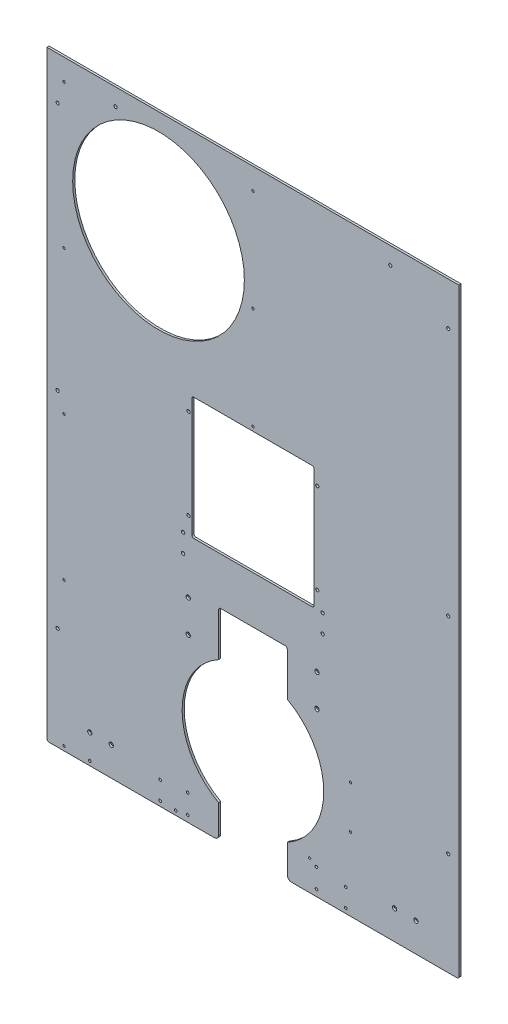
from build123d import *

# Parameters (mm, degrees)
SKETCH1_W                                     = 1219.2
SKETCH1_H                                     = 1778
SKETCH1_R                                     = 254
SKETCH1_W_2                                   = 361.95
SKETCH1_H_2                                   = 361.95
BOSS_EXTRUDE1_DEPTH                           = 6.35
SKETCH3_R                                     = 209.55
CUT_EXTRUDE2_DEPTH                            = 7.35
SKETCH2_W                                     = 203.2
SKETCH2_H                                     = 165.1
CUT_EXTRUDE1_DEPTH                            = 7.35
SKETCH4_R                                     = 3.3655
CUT_EXTRUDE3_DEPTH                            = 7.35
LPATTERN1_COUNT                               = 5
LPATTERN1_PITCH                               = 425.45
SKETCH5_R                                     = 3.429
CUT_EXTRUDE4_DEPTH                            = 7.35
LPATTERN2_COUNT                               = 3
LPATTERN2_PITCH                               = 301.625
SKETCH6_R                                     = 3.96875
CUT_EXTRUDE5_DEPTH                            = 7.35
SKETCH7_R                                     = 3.3782
CUT_EXTRUDE6_DEPTH                            = 7.35
CSK_FOR_1_4_FLAT_HEAD_MACHINE_SCREW1_AT_COUNT = 2
CSK_FOR_1_4_FLAT_HEAD_MACHINE_SCREW1_AT_PITCH = 63.5
LPATTERN3_COUNT                               = 2
LPATTERN3_PITCH                               = 901.7
SKETCH12_R                                    = 4.7625
CUT_EXTRUDE7_DEPTH                            = 7.35
SKETCH14_R                                    = 4.7625
CUT_EXTRUDE8_DEPTH                            = 7.35
SKETCH15_R                                    = 4.7625
CUT_EXTRUDE9_DEPTH                            = 7.35
SKETCH16_R                                    = 4.7625
CUT_EXTRUDE10_DEPTH                           = 7.35
FILLET1_R                                     = 12.7
FILLET2_R                                     = 6.35
SKETCH17_R                                    = 3.937
CUT_EXTRUDE11_DEPTH                           = 7.35
CSK_FOR_1_4_FLAT_HEAD_MACHINE_SCREW2_AT_COUNT = 2
CSK_FOR_1_4_FLAT_HEAD_MACHINE_SCREW2_AT_PITCH = 95.25
CSK_FOR_1_4_FLAT_HEAD_MACHINE_SCREW2_2_COUNT  = 2
CSK_FOR_1_4_FLAT_HEAD_MACHINE_SCREW2_2_PITCH  = 381
CSK_FOR_1_4_FLAT_HEAD_MACHINE_SCREW2_3_COUNT  = 2
CSK_FOR_1_4_FLAT_HEAD_MACHINE_SCREW2_3_PITCH  = 392.72581084
F_5_16_0_3125_DIAMETER_HOLE1_D                = 7.9375


with BuildPart() as part:
    # Sketch1 → Boss-Extrude1 (new body)
    with BuildSketch(Plane.XY):
        with Locations((609.6, 889)):
            Rectangle(SKETCH1_W, SKETCH1_H)
        with Locations((330.2, 1473.2)):
            Circle(SKETCH1_R, mode=Mode.SUBTRACT)
        with Locations((609.6, 917.575)):
            Rectangle(SKETCH1_W_2, SKETCH1_H_2, mode=Mode.SUBTRACT)
    extrude(amount=BOSS_EXTRUDE1_DEPTH)

    # Sketch3 → Cut-Extrude2 (cut, through all)
    with BuildSketch(Plane.XY.offset(6.35)):
        with Locations((609.6, 279.4)):
            Circle(SKETCH3_R)
    extrude(amount=-CUT_EXTRUDE2_DEPTH, mode=Mode.SUBTRACT)

    # Sketch2 → Cut-Extrude1 (cut, through all)
    with BuildSketch(Plane.XY.offset(6.35)):
        with Locations((609.6, 44.45)):
            Rectangle(SKETCH2_W, SKETCH2_H)
        with Locations((609.6, 514.35)):
            Rectangle(SKETCH2_W, SKETCH2_H)
    extrude(amount=-CUT_EXTRUDE1_DEPTH, mode=Mode.SUBTRACT)

    # Sketch4 → Cut-Extrude3 (cut, through all)
    with BuildSketch(Plane.XY.offset(6.35)):
        with Locations((50.8, 12.7)):
            Circle(SKETCH4_R)
    cut_extrude3 = extrude(amount=-CUT_EXTRUDE3_DEPTH, mode=Mode.SUBTRACT)

    # LPattern1: Cut-Extrude3 ×5
    with Locations(*[(0, i * LPATTERN1_PITCH, 0) for i in range(1, LPATTERN1_COUNT)]):
        add(cut_extrude3, mode=Mode.SUBTRACT)

    # Sketch5 → Cut-Extrude4 (cut, through all)
    with BuildSketch(Plane.XY.offset(6.35)):
        with Locations((609.6, 1714.5)):
            Circle(SKETCH5_R)
    cut_extrude4 = extrude(amount=-CUT_EXTRUDE4_DEPTH, mode=Mode.SUBTRACT)

    # LPattern2: Cut-Extrude4 ×3
    with Locations(*[(0, -i * LPATTERN2_PITCH, 0) for i in range(1, LPATTERN2_COUNT)]):
        add(cut_extrude4, mode=Mode.SUBTRACT)

    # Sketch6 → Cut-Extrude5 (cut, through all)
    with BuildSketch(Plane.XY.offset(6.35)):
        with Locations((127, 12.7)):
            Circle(SKETCH6_R)
        with Locations((381, 12.7)):
            Circle(SKETCH6_R)
    extrude(amount=-CUT_EXTRUDE5_DEPTH, mode=Mode.SUBTRACT)

    # Sketch7 → Cut-Extrude6 (cut, through all)
    with BuildSketch(Plane.XY.offset(6.35)):
        with Locations((777.605208253, 88.9)):
            Circle(SKETCH7_R)
        with Locations((898.525, 342.9)):
            Circle(SKETCH7_R)
        with Locations((898.525, 215.9)):
            Circle(SKETCH7_R)
    extrude(amount=-CUT_EXTRUDE6_DEPTH, mode=Mode.SUBTRACT)

    # Sketch11 → CSK for 1/4 Flat Head Machine Screw1 (revolve, cut)
    with BuildSketch(Plane(origin=(127, 85.725, 6.35), x_dir=(0, -1, 0), z_dir=(1, 0, 0))):
        Polygon((0, 0), (0, 6.35), (3.57124, 6.35), (3.57124, 3.298865467), (6.4389, 0), align=None)
    csk_for_1_4_flat_head_machine_screw1 = revolve(axis=Axis((127, 85.725, 12.7), (0, 0, -1)), mode=Mode.SUBTRACT)

    # CSK for 1/4 Flat Head Machine Screw1 at: CSK for 1/4 Flat Head Machine Screw1 ×2
    with Locations(*[(i * CSK_FOR_1_4_FLAT_HEAD_MACHINE_SCREW1_AT_PITCH, 0, 0) for i in range(1, CSK_FOR_1_4_FLAT_HEAD_MACHINE_SCREW1_AT_COUNT)]):
        add(csk_for_1_4_flat_head_machine_screw1, mode=Mode.SUBTRACT)

    # LPattern3: CSK for 1/4 Flat Head Machine Screw1 ×2
    with Locations(*[(i * LPATTERN3_PITCH, 0, 0) for i in range(1, LPATTERN3_COUNT)]):
        add(csk_for_1_4_flat_head_machine_screw1, mode=Mode.SUBTRACT)

    # LPattern3 copy 1 sketch → LPattern3 copy 1 (revolve, cut)
    with BuildSketch(Plane(origin=(1092.2, 85.725, 6.35), x_dir=(0, -1, 0), z_dir=(1, 0, 0))):
        Polygon((0, 0), (0, 6.35), (3.57124, 6.35), (3.57124, 3.298865467), (6.4389, 0), align=None)
    revolve(axis=Axis((1092.2, 85.725, 12.7), (0, 0, -1)), mode=Mode.SUBTRACT)

    # Sketch12 → Cut-Extrude7 (cut, through all)
    with BuildSketch(Plane.XY.offset(6.35)):
        with Locations((203.2, 1727.2)):
            Circle(SKETCH12_R)
        with Locations((1016, 1727.2)):
            Circle(SKETCH12_R)
    extrude(amount=-CUT_EXTRUDE7_DEPTH, mode=Mode.SUBTRACT)

    # Sketch14 → Cut-Extrude8 (cut, through all)
    with BuildSketch(Plane.XY.offset(6.35)):
        with Locations((31.75, 1651)):
            Circle(SKETCH14_R)
        with Locations((31.75, 914.4)):
            Circle(SKETCH14_R)
        with Locations((31.75, 304.8)):
            Circle(SKETCH14_R)
    cut_extrude8 = extrude(amount=-CUT_EXTRUDE8_DEPTH, mode=Mode.SUBTRACT)

    # Mirror1: Cut-Extrude8 across plane
    add(cut_extrude8.mirror(Plane.ZY.offset(-609.6)), mode=Mode.SUBTRACT)

    # Sketch15 → Cut-Extrude9 (cut, through all)
    with BuildSketch(Plane.XY.offset(6.35)):
        with Locations((403.225, 736.6)):
            Circle(SKETCH15_R)
        with Locations((403.225, 682.625)):
            Circle(SKETCH15_R)
    cut_extrude9 = extrude(amount=-CUT_EXTRUDE9_DEPTH, mode=Mode.SUBTRACT)

    # Mirror2: Cut-Extrude9 across plane
    add(cut_extrude9.mirror(Plane.ZY.offset(-609.6)), mode=Mode.SUBTRACT)

    # Sketch16 → Cut-Extrude10 (cut, through all)
    with BuildSketch(Plane.XY.offset(6.35)):
        with Locations((419.1, 1054.1)):
            Circle(SKETCH16_R)
        with Locations((419.1, 787.4)):
            Circle(SKETCH16_R)
        with Locations((800.1, 1054.1)):
            Circle(SKETCH16_R)
        with Locations((800.1, 787.4)):
            Circle(SKETCH16_R)
    extrude(amount=-CUT_EXTRUDE10_DEPTH, mode=Mode.SUBTRACT)

    # Fillet1
    fillet1_edges = [part.edges().sort_by_distance(p)[0] for p in [
        (508, 0, 3.175),
        (711.2, 0, 3.175),
    ]]
    fillet(fillet1_edges, radius=FILLET1_R)

    # Fillet2
    fillet2_edges = [part.edges().sort_by_distance(p)[0] for p in [
        (428.625, 1098.55, 3.175),
        (428.625, 736.6, 3.175),
        (790.575, 736.6, 3.175),
        (790.575, 1098.55, 3.175),
        (711.2, 596.9, 3.175),
        (508, 596.9, 3.175),
        (0, 0, 3.175),
        (1219.2, 0, 3.175),
    ]]
    fillet(fillet2_edges, radius=FILLET2_R)

    # Sketch17 → Cut-Extrude11 (cut, through all)
    with BuildSketch(Plane.XY.offset(6.35)):
        with Locations((416.56762, 76.2)):
            Circle(SKETCH17_R)
        with Locations((416.56762, 19.05)):
            Circle(SKETCH17_R)
        with Locations((797.56762, 19.05)):
            Circle(SKETCH17_R)
        with Locations((797.56762, 76.2)):
            Circle(SKETCH17_R)
    extrude(amount=-CUT_EXTRUDE11_DEPTH, mode=Mode.SUBTRACT)

    # Sketch21 → CSK for 1/4 Flat Head Machine Screw2 (revolve, cut)
    with BuildSketch(Plane(origin=(418.15512, 576.972045059, 6.35), x_dir=(0, -1, 0), z_dir=(1, 0, 0))):
        Polygon((0, 0), (0, 6.35), (3.57124, 6.35), (3.57124, 3.298865467), (6.4389, 0), align=None)
    csk_for_1_4_flat_head_machine_screw2 = revolve(axis=Axis((418.15512, 576.972045059, 12.7), (0, 0, -1)), mode=Mode.SUBTRACT)

    # CSK for 1/4 Flat Head Machine Screw2 at: CSK for 1/4 Flat Head Machine Screw2 ×2
    with Locations(*[(0, -i * CSK_FOR_1_4_FLAT_HEAD_MACHINE_SCREW2_AT_PITCH, 0) for i in range(1, CSK_FOR_1_4_FLAT_HEAD_MACHINE_SCREW2_AT_COUNT)]):
        add(csk_for_1_4_flat_head_machine_screw2, mode=Mode.SUBTRACT)

    # CSK for 1_4 Flat Head Machine Screw2 2: CSK for 1/4 Flat Head Machine Screw2 ×2
    with Locations(*[(i * CSK_FOR_1_4_FLAT_HEAD_MACHINE_SCREW2_2_PITCH, 0, 0) for i in range(1, CSK_FOR_1_4_FLAT_HEAD_MACHINE_SCREW2_2_COUNT)]):
        add(csk_for_1_4_flat_head_machine_screw2, mode=Mode.SUBTRACT)

    # CSK for 1_4 Flat Head Machine Screw2 3: CSK for 1/4 Flat Head Machine Screw2 ×2
    with Locations(*[Vector(0.9701425, -0.242535625, 0) * (i * CSK_FOR_1_4_FLAT_HEAD_MACHINE_SCREW2_3_PITCH) for i in range(1, CSK_FOR_1_4_FLAT_HEAD_MACHINE_SCREW2_3_COUNT)]):
        add(csk_for_1_4_flat_head_machine_screw2, mode=Mode.SUBTRACT)

    # 5/16 (0.3125) Diameter Hole1 (through all)
    with Locations(Plane.XY.offset(6.35)):
        with Locations((334.9625, 68.2625), (334.9625, 14.2875), (884.2375, 14.2875), (884.2375, 68.2625)):
            Hole(F_5_16_0_3125_DIAMETER_HOLE1_D / 2)


solid = part.part
